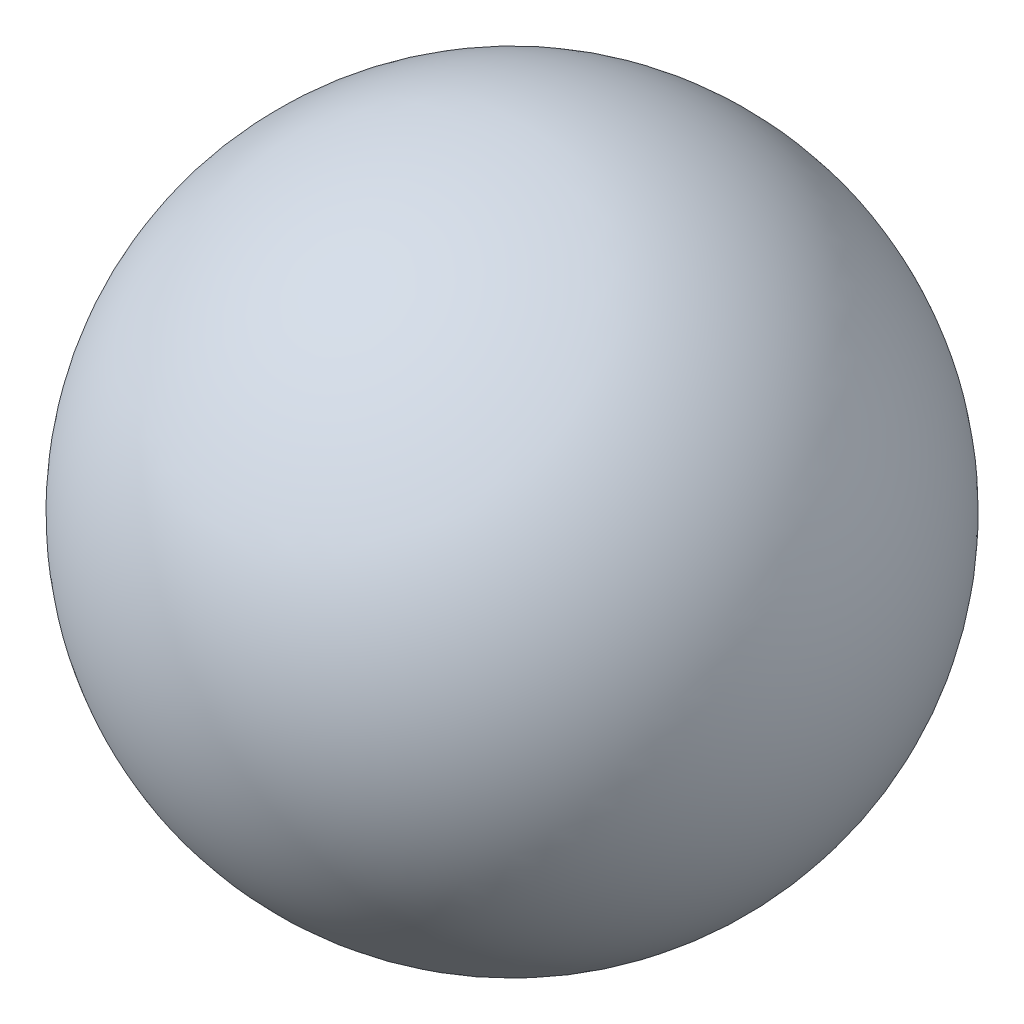
from build123d import *


with BuildPart() as part:
    # Sketch1 → Revolve1 (revolve)
    with BuildSketch(Plane(origin=(0, 0, 0), x_dir=(1, 0, 0), z_dir=(0, 1, 0))):
        with BuildLine():
            Line((0, 0), (0, 1.9))
            ThreePointArc((0, 1.9), (-0.95, 0.95), (0, 0))
        make_face()
    revolve(axis=Axis((0, 0, 0), (0, 0, -1)))


solid = part.part
